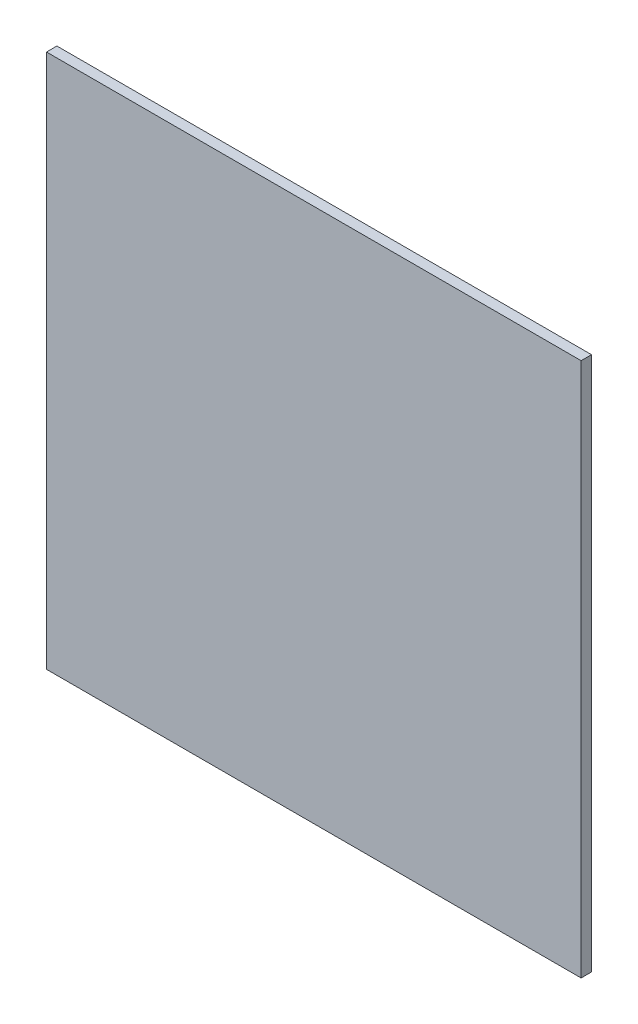
from build123d import *

# Parameters (mm, degrees)
SKETCH1_W      = 88.9
SKETCH1_H      = 88.9
EXTRUDE1_DEPTH = 1.7272


with BuildPart() as part:
    # Sketch1 → Extrude1 (new body)
    with BuildSketch(Plane.XY):
        Rectangle(SKETCH1_W, SKETCH1_H)
    extrude(amount=EXTRUDE1_DEPTH)


solid = part.part
